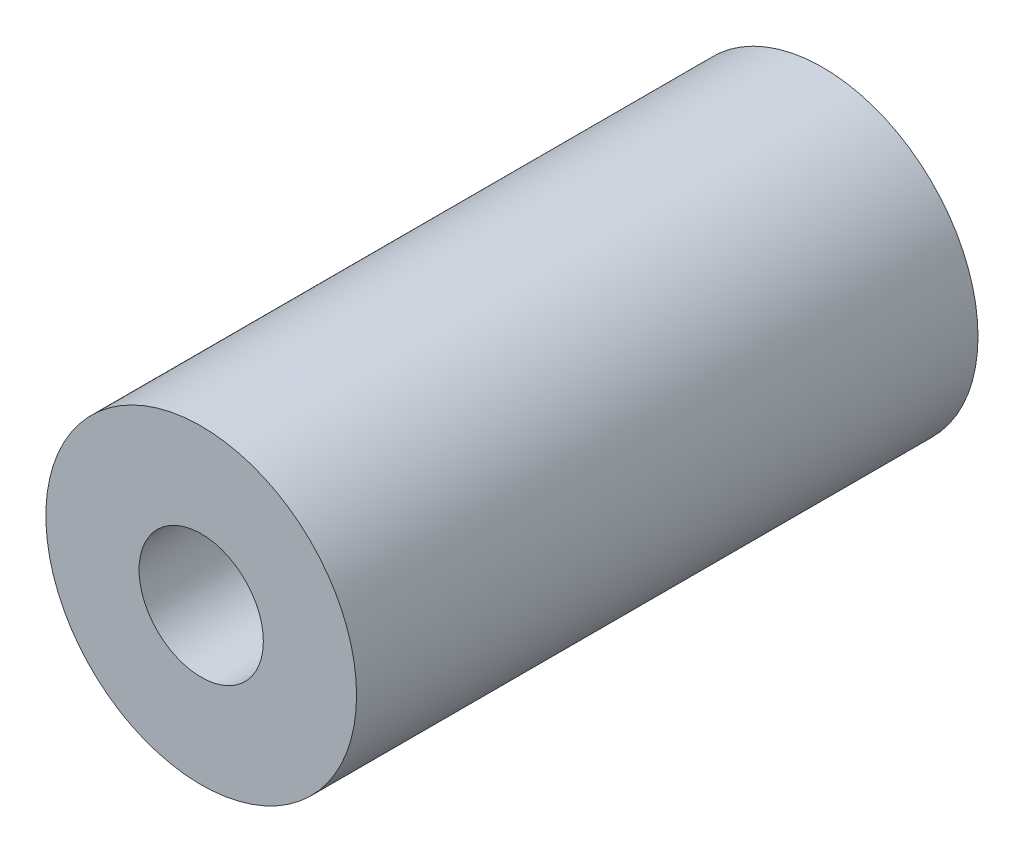
from build123d import *

# Parameters (mm, degrees)
BASE_SKETCH_R          = 2.5
BASE_SKETCH_R_2        = 1
EXTRUDE_PIN_BODY_DEPTH = 10


with BuildPart() as part:
    # Base Sketch → Extrude Pin Body (new body)
    with BuildSketch(Plane.XY):
        Circle(BASE_SKETCH_R)
        Circle(BASE_SKETCH_R_2, mode=Mode.SUBTRACT)
    extrude(amount=EXTRUDE_PIN_BODY_DEPTH)


solid = part.part
